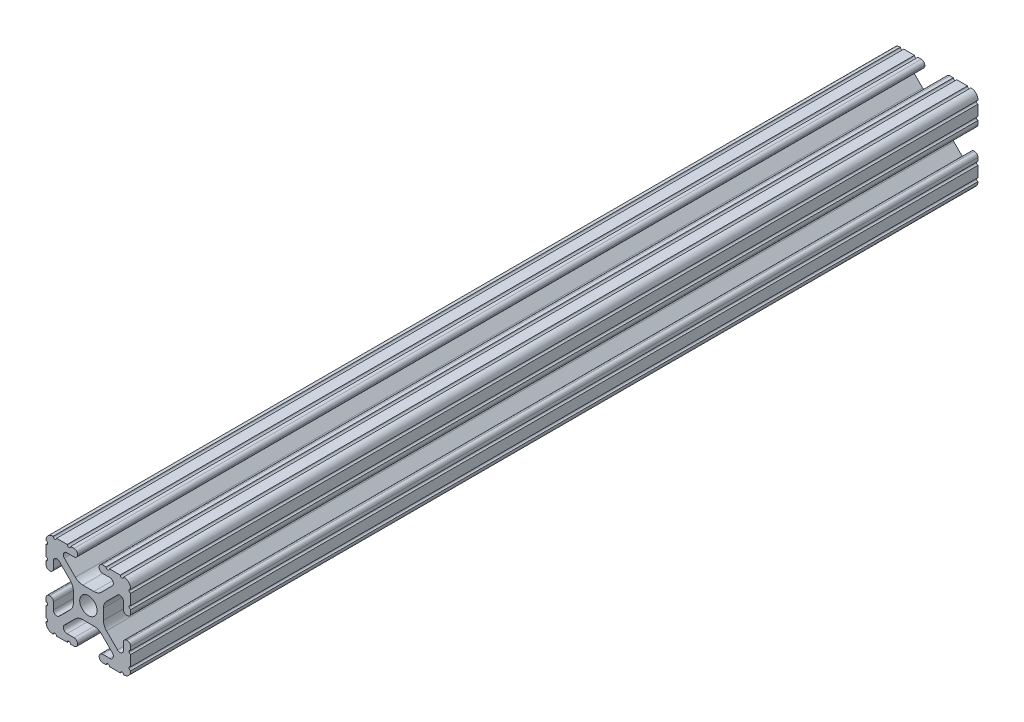
from build123d import *

# Parameters (mm, degrees)
SKETCH1_R           = 2.6035
BOSS_EXTRUDE1_DEPTH = 127


with BuildPart() as part:
    # Sketch1 → Boss-Extrude1 (new body, symmetric)
    with BuildSketch(Plane.XY):
        with BuildLine():
            Line((-7.179650497, -8.645192506), (-3.952270251, -5.423690499))
            ThreePointArc((-3.952270251, -5.423690499), (-2.922936451, -4.736929036), (-1.709253557, -4.4958))
            Line((-1.709253557, -4.4958), (1.709253557, -4.4958))
            ThreePointArc((1.709253557, -4.4958), (2.922936451, -4.736929036), (3.952270251, -5.423690499))
            Line((3.952270251, -5.423690499), (7.179650497, -8.645192506))
            ThreePointArc((7.179650497, -8.645192506), (7.41473083, -9.822813117), (6.416408329, -10.4902))
            Line((6.416408329, -10.4902), (4.287512407, -10.4902))
            ThreePointArc((4.287512407, -10.4902), (3.54574862, -10.79744862), (3.2385, -11.539212407))
            Line((3.2385, -11.539212407), (3.2385, -11.650987593))
            ThreePointArc((3.2385, -11.650987593), (3.54574862, -12.39275138), (4.287512407, -12.7))
            Line((4.287512407, -12.7), (5.317126718, -12.7))
            ThreePointArc((5.317126718, -12.7), (5.825126718, -12.192), (6.333126718, -12.7))
            Line((6.333126718, -12.7), (9.550443118, -12.7))
            ThreePointArc((9.550443118, -12.7), (10.058366869, -12.192000006), (10.566443095, -12.699847501))
            ThreePointArc((10.566443095, -12.699847501), (12.082537762, -12.08250727), (12.699846982, -10.566399977))
            ThreePointArc((12.699846982, -10.566399977), (12.192000006, -10.058323491), (12.7, -9.5504))
            Line((12.7, -9.5504), (12.7, -6.3330836))
            ThreePointArc((12.7, -6.3330836), (12.192, -5.8250836), (12.7, -5.3170836))
            Line((12.7, -5.3170836), (12.7, -4.287469289))
            ThreePointArc((12.7, -4.287469289), (12.39275138, -3.545705502), (11.650987593, -3.238456882))
            Line((11.650987593, -3.238456882), (11.539212407, -3.238456882))
            ThreePointArc((11.539212407, -3.238456882), (10.79744862, -3.545705502), (10.4902, -4.287469289))
            Line((10.4902, -4.287469289), (10.4902, -6.402089023))
            ThreePointArc((10.4902, -6.402089023), (9.856505071, -7.351067942), (8.737131347, -7.129408934))
            Line((8.737131347, -7.129408934), (5.441005833, -3.840816462))
            ThreePointArc((5.441005833, -3.840816462), (4.750877967, -2.809883091), (4.5085, -1.593185507))
            Line((4.5085, -1.593185507), (4.5085, 1.593185507))
            ThreePointArc((4.5085, 1.593185507), (4.750877967, 2.809883091), (5.441005833, 3.840816462))
            Line((5.441005833, 3.840816462), (8.737131347, 7.129408934))
            ThreePointArc((8.737131347, 7.129408934), (9.856505071, 7.351067942), (10.4902, 6.402089023))
            Line((10.4902, 6.402089023), (10.4902, 4.287469289))
            ThreePointArc((10.4902, 4.287469289), (10.79744862, 3.545705502), (11.539212407, 3.238456882))
            Line((11.539212407, 3.238456882), (11.650987593, 3.238456882))
            ThreePointArc((11.650987593, 3.238456882), (12.39275138, 3.545705502), (12.7, 4.287469289))
            Line((12.7, 4.287469289), (12.7, 5.3170836))
            ThreePointArc((12.7, 5.3170836), (12.192, 5.8250836), (12.7, 6.3330836))
            Line((12.7, 6.3330836), (12.7, 9.5504))
            ThreePointArc((12.7, 9.5504), (12.192000006, 10.058323491), (12.699846982, 10.566399977))
            ThreePointArc((12.699846982, 10.566399977), (12.082537762, 12.08250727), (10.566443095, 12.699847501))
            ThreePointArc((10.566443095, 12.699847501), (10.058366869, 12.192000006), (9.550443118, 12.7))
            Line((9.550443118, 12.7), (6.333126718, 12.7))
            ThreePointArc((6.333126718, 12.7), (5.825126718, 12.192), (5.317126718, 12.7))
            Line((5.317126718, 12.7), (4.287512407, 12.7))
            ThreePointArc((4.287512407, 12.7), (3.54574862, 12.39275138), (3.2385, 11.650987593))
            Line((3.2385, 11.650987593), (3.2385, 11.539212407))
            ThreePointArc((3.2385, 11.539212407), (3.54574862, 10.79744862), (4.287512407, 10.4902))
            Line((4.287512407, 10.4902), (6.476788598, 10.4902))
            ThreePointArc((6.476788598, 10.4902), (7.432222385, 9.85140422), (7.207036008, 8.724370562))
            Line((7.207036008, 8.724370562), (3.898272566, 5.423169045))
            ThreePointArc((3.898272566, 5.423169045), (2.869120213, 4.736787962), (1.655778399, 4.4958))
            Line((1.655778399, 4.4958), (-1.655778399, 4.4958))
            ThreePointArc((-1.655778399, 4.4958), (-2.869120213, 4.736787962), (-3.898272566, 5.423169045))
            Line((-3.898272566, 5.423169045), (-7.207036008, 8.724370562))
            ThreePointArc((-7.207036008, 8.724370562), (-7.432222385, 9.85140422), (-6.476788598, 10.4902))
            Line((-6.476788598, 10.4902), (-4.287512407, 10.4902))
            ThreePointArc((-4.287512407, 10.4902), (-3.54574862, 10.79744862), (-3.2385, 11.539212407))
            Line((-3.2385, 11.539212407), (-3.2385, 11.650987593))
            ThreePointArc((-3.2385, 11.650987593), (-3.54574862, 12.39275138), (-4.287512407, 12.7))
            Line((-4.287512407, 12.7), (-5.317126718, 12.7))
            ThreePointArc((-5.317126718, 12.7), (-5.825126718, 12.192), (-6.333126718, 12.7))
            Line((-6.333126718, 12.7), (-9.550443118, 12.7))
            ThreePointArc((-9.550443118, 12.7), (-10.058366869, 12.192000006), (-10.566443095, 12.699847501))
            ThreePointArc((-10.566443095, 12.699847501), (-12.082537762, 12.08250727), (-12.699846982, 10.566399977))
            ThreePointArc((-12.699846982, 10.566399977), (-12.192000006, 10.058323491), (-12.7, 9.5504))
            Line((-12.7, 9.5504), (-12.7, 6.3330836))
            ThreePointArc((-12.7, 6.3330836), (-12.192, 5.8250836), (-12.7, 5.3170836))
            Line((-12.7, 5.3170836), (-12.7, 4.287469289))
            ThreePointArc((-12.7, 4.287469289), (-12.39275138, 3.545705502), (-11.650987593, 3.238456882))
            Line((-11.650987593, 3.238456882), (-11.539212407, 3.238456882))
            ThreePointArc((-11.539212407, 3.238456882), (-10.79744862, 3.545705502), (-10.4902, 4.287469289))
            Line((-10.4902, 4.287469289), (-10.4902, 6.402089023))
            ThreePointArc((-10.4902, 6.402089023), (-9.856505071, 7.351067942), (-8.737131347, 7.129408934))
            Line((-8.737131347, 7.129408934), (-5.441005833, 3.840816462))
            ThreePointArc((-5.441005833, 3.840816462), (-4.750877967, 2.809883091), (-4.5085, 1.593185507))
            Line((-4.5085, 1.593185507), (-4.5085, -1.593185507))
            ThreePointArc((-4.5085, -1.593185507), (-4.750877967, -2.809883091), (-5.441005833, -3.840816462))
            Line((-5.441005833, -3.840816462), (-8.737131347, -7.129408934))
            ThreePointArc((-8.737131347, -7.129408934), (-9.856505071, -7.351067942), (-10.4902, -6.402089023))
            Line((-10.4902, -6.402089023), (-10.4902, -4.287469289))
            ThreePointArc((-10.4902, -4.287469289), (-10.79744862, -3.545705502), (-11.539212407, -3.238456882))
            Line((-11.539212407, -3.238456882), (-11.650987593, -3.238456882))
            ThreePointArc((-11.650987593, -3.238456882), (-12.39275138, -3.545705502), (-12.7, -4.287469289))
            Line((-12.7, -4.287469289), (-12.7, -5.3170836))
            ThreePointArc((-12.7, -5.3170836), (-12.192, -5.8250836), (-12.7, -6.3330836))
            Line((-12.7, -6.3330836), (-12.7, -9.5504))
            ThreePointArc((-12.7, -9.5504), (-12.192000006, -10.058323491), (-12.699846982, -10.566399977))
            ThreePointArc((-12.699846982, -10.566399977), (-12.082537762, -12.08250727), (-10.566443095, -12.699847501))
            ThreePointArc((-10.566443095, -12.699847501), (-10.058366869, -12.192000006), (-9.550443118, -12.7))
            Line((-9.550443118, -12.7), (-6.333126718, -12.7))
            ThreePointArc((-6.333126718, -12.7), (-5.825126718, -12.192), (-5.317126718, -12.7))
            Line((-5.317126718, -12.7), (-4.287512407, -12.7))
            ThreePointArc((-4.287512407, -12.7), (-3.54574862, -12.39275138), (-3.2385, -11.650987593))
            Line((-3.2385, -11.650987593), (-3.2385, -11.539212407))
            ThreePointArc((-3.2385, -11.539212407), (-3.54574862, -10.79744862), (-4.287512407, -10.4902))
            Line((-4.287512407, -10.4902), (-6.416408329, -10.4902))
            ThreePointArc((-6.416408329, -10.4902), (-7.41473083, -9.822813117), (-7.179650497, -8.645192506))
        make_face()
        Circle(SKETCH1_R, mode=Mode.SUBTRACT)
    extrude(amount=BOSS_EXTRUDE1_DEPTH, both=True)


solid = part.part
